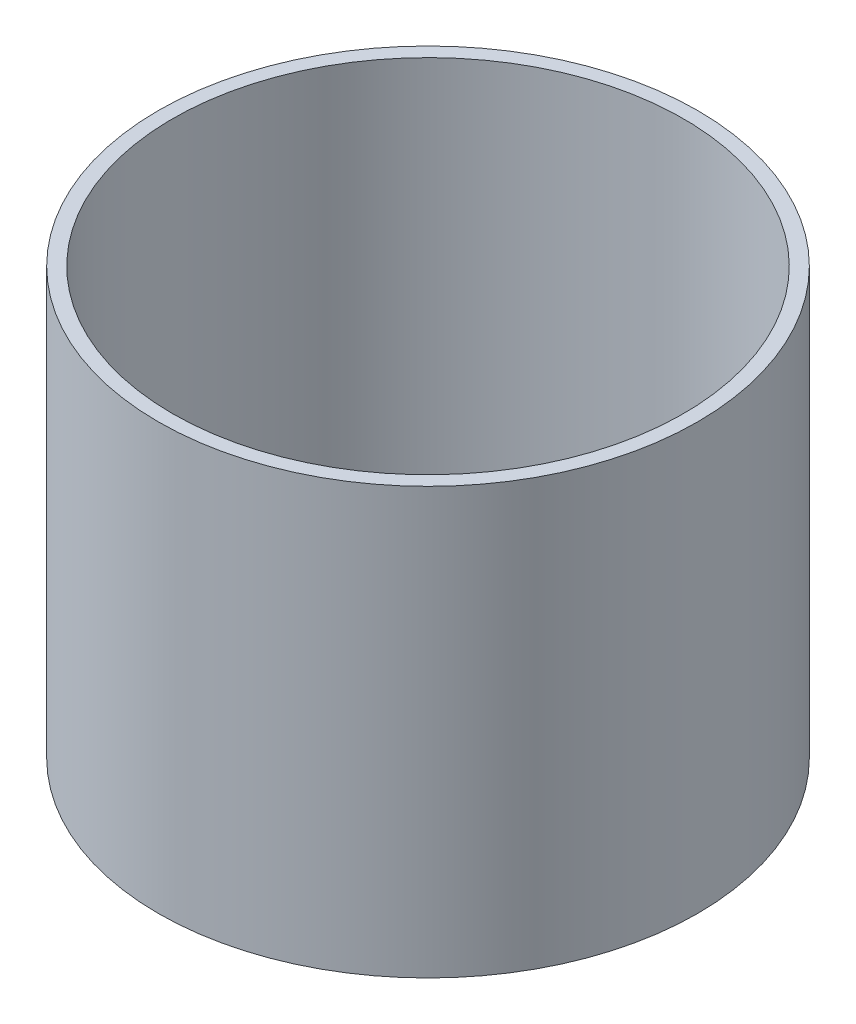
from build123d import *

# Parameters (mm, degrees)
SKETCH1_R           = 95
SKETCH1_R_2         = 90
BOSS_EXTRUDE1_DEPTH = 150


with BuildPart() as part:
    # Sketch1 → Boss-Extrude1 (new body)
    with BuildSketch(Plane(origin=(0, 0, 0), x_dir=(1, 0, 0), z_dir=(0, 1, 0))):
        Circle(SKETCH1_R)
        Circle(SKETCH1_R_2, mode=Mode.SUBTRACT)
    extrude(amount=BOSS_EXTRUDE1_DEPTH)


solid = part.part
